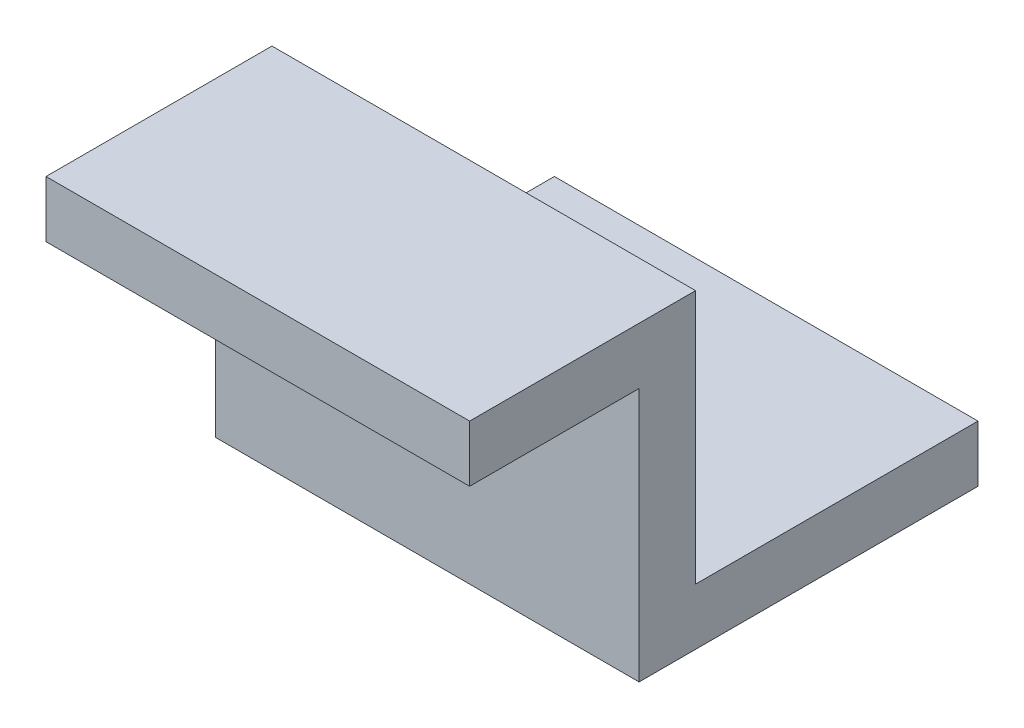
from build123d import *

# Parameters (mm, degrees)
BOSS_EXTRUDE1_DEPTH = 15
CUT_EXTRUDE1_REACH  = 4
SKETCH3_R           = 1.5


with BuildPart() as part:
    # Sketch1 → Boss-Extrude1 (new body)
    with BuildSketch(Plane(origin=(0, 0, 0), x_dir=(0, 0, -1), z_dir=(1, 0, 0))):
        Polygon((0, 0), (8, 0), (8, -9), (18, -9), (18, -11), (6, -11), (6, -2), (0, -2), align=None)
    extrude(amount=-BOSS_EXTRUDE1_DEPTH)

    # Sketch3 → Cut-Extrude1 (cut, up to next)
    with BuildSketch(Plane(origin=(0, -9, 0), x_dir=(1, 0, 0), z_dir=(0, 1, 0)), mode=Mode.PRIVATE) as cut_extrude1_sk1:
        with Locations((-7.5, 13)):
            Circle(SKETCH3_R)
    cut_extrude1_tool1 = extrude(cut_extrude1_sk1.sketch, amount=-CUT_EXTRUDE1_REACH, mode=Mode.PRIVATE) & part.part
    add(cut_extrude1_tool1.solids().sort_by_distance((-7.5, -9, -13))[0], mode=Mode.SUBTRACT)


solid = part.part
